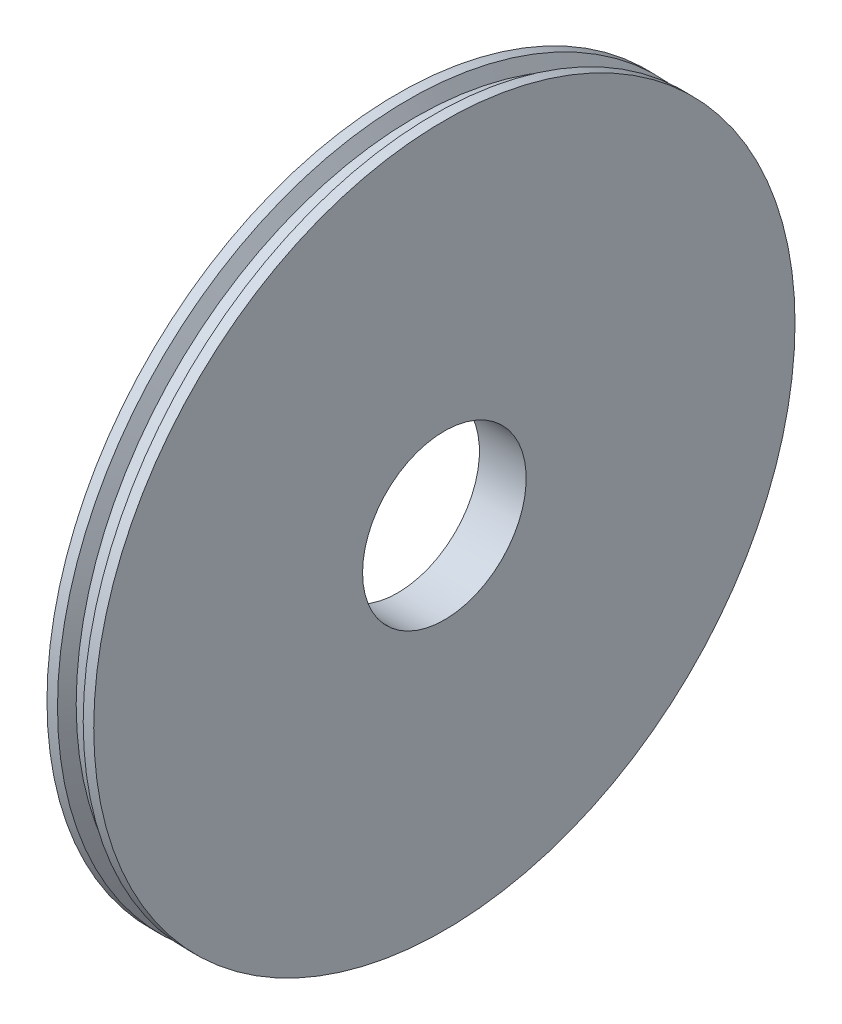
from build123d import *


with BuildPart() as part:
    # Skica1 → Rotovat1 (revolve)
    with BuildSketch(Plane.XY):
        Polygon((-10, 35), (-10, 150), (-5.5, 150), (-2.5, 145), (2.5, 145), (5.5, 150), (10, 150), (10, 35), align=None)
    revolve(axis=Axis((-72.519650029, 0, 0), (1, 0, 0)))


solid = part.part
